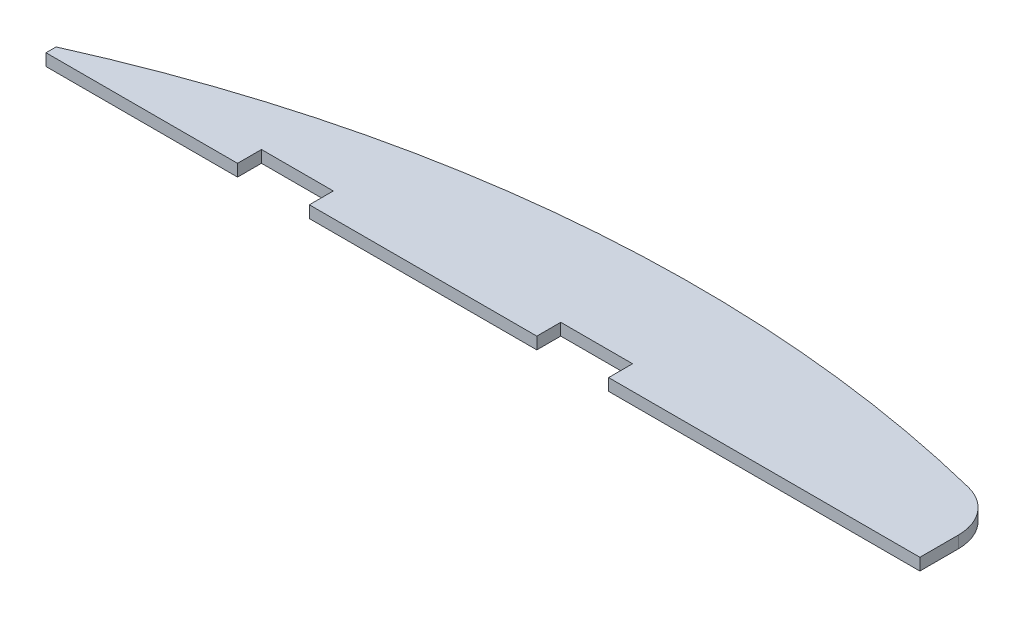
from build123d import *

# Parameters (mm, degrees)
EXTRUDE_1_DEPTH     = 1
SKETCH_2_W          = 6
SKETCH_2_H          = 4
CUT_EXTRUDE_1_DEPTH = 2
FILLET_1_R          = 4


with BuildPart() as part:
    # 草图1 → 凸台-拉伸1 (new body)
    with BuildSketch(Plane(origin=(0, 0, 0), x_dir=(1, 0, 0), z_dir=(0, 1, 0))):
        with BuildLine():
            Line((-30, -3), (-44, -3))
            Line((-44, -3), (-44, -2.158291102))
            ThreePointArc((-44, -2.158291102), (-7.97872831, 6.982895336), (29, 3.286010669))
            Line((29, 3.286010669), (29, -3))
            Line((29, -3), (0, -3))
            Line((0, -3), (-30, -3))
        make_face()
    extrude(amount=EXTRUDE_1_DEPTH)

    # 草图2 → 切除-拉伸1 (cut, through all)
    with BuildSketch(Plane.XZ):
        with Locations((0, 3)):
            Rectangle(SKETCH_2_W, SKETCH_2_H)
        with Locations((-25, 3)):
            Rectangle(SKETCH_2_W, SKETCH_2_H)
    extrude(amount=-CUT_EXTRUDE_1_DEPTH, mode=Mode.SUBTRACT)

    # 圆角1
    fillet_1_edges = [part.edges().sort_by_distance(p)[0] for p in [
        (29, 0.5, -3.286010669),
    ]]
    fillet(fillet_1_edges, radius=FILLET_1_R)


solid = part.part
